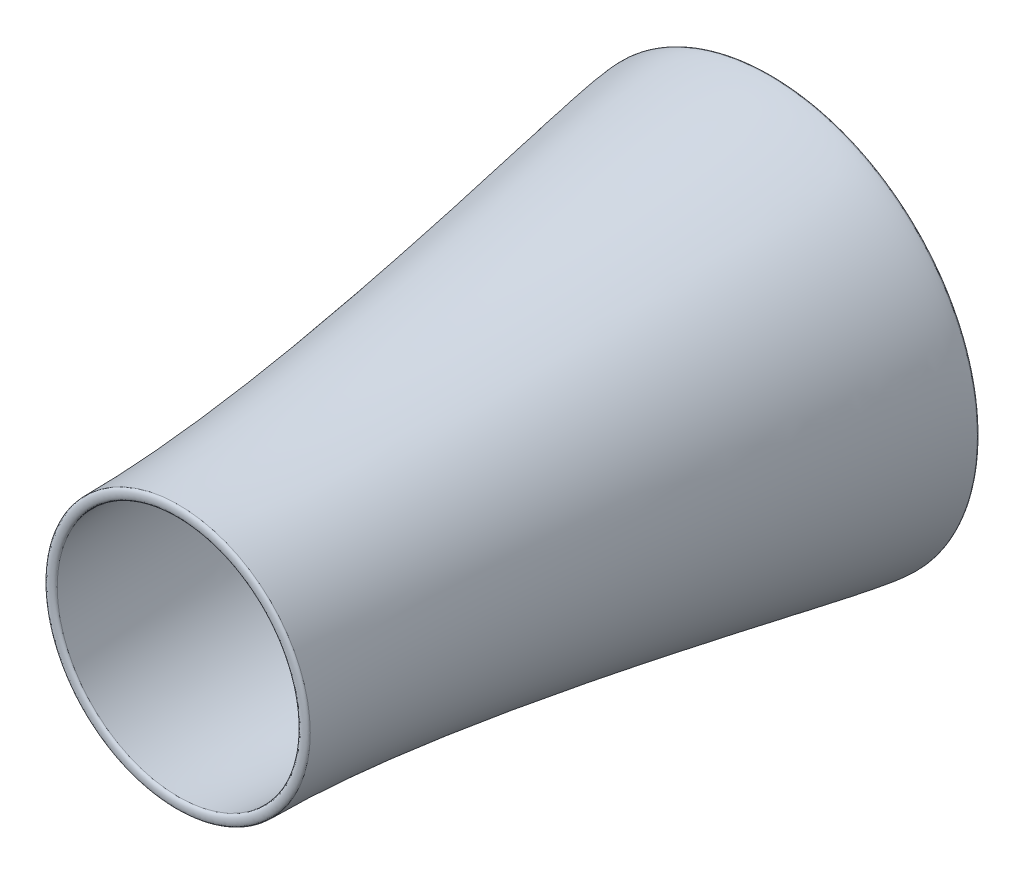
from build123d import *


with BuildPart() as part:
    # Sketch21 → Revolve2 (revolve)
    with BuildSketch(Plane(origin=(0, 0, 0), x_dir=(1, 0, 0), z_dir=(0, 1, 0))):
        with BuildLine():
            Line((-414.489662379, -2018.659396945), (-450.143329298, -2018.659396945))
            add(Edge.make_bspline(
                [(-711.609923736, -0.893759873), (-711.609923736, -126.27771225), (-450.143329298, -1288.35027656), (-450.143329298, -2018.659396945)],
                knots=[0, 0, 0, 0, 1, 1, 1, 1], degree=3))
            Line((-711.609923736, -0.893759873), (-622.148368512, -0.893759873))
            add(Edge.make_bspline(
                [(-622.148368512, -0.893759873), (-512.587421425, -283.558787507), (-414.972940266, -786.375242865), (-442.508967605, -1553.960293497), (-414.489662379, -2018.659396945)],
                knots=[0, 0, 0, 0, 0.206506907, 1, 1, 1, 1], degree=3))
        make_face()
    revolve(axis=Axis((0, 0, 99.684784321), (0, 0, -1)))


with BuildPart() as body_2:
    # Sketch22 → Revolve3 (revolve)
    with BuildSketch(Plane(origin=(0, 0, 0), x_dir=(1, 0, 0), z_dir=(0, 1, 0))):
        with BuildLine():
            Line((-711.609923736, -0.893759873), (-622.148368512, -0.893759873))
            add(Edge.make_bspline(
                [(-711.609923736, -0.893759873), (-711.609923736, 16.03957346), (-622.148368512, 16.03957346), (-622.148368512, -0.893759873)],
                knots=[0, 0, 0, 0, 1, 1, 1, 1], degree=3))
        make_face()
    revolve(axis=Axis((0, 0, 99.684784321), (0, 0, -1)))


with BuildPart() as body_3:
    # Sketch23 → Revolve4 (revolve)
    with BuildSketch(Plane(origin=(0, 0, 0), x_dir=(1, 0, 0), z_dir=(0, 1, 0))):
        with BuildLine():
            Line((-450.143329298, -2018.659396945), (-414.489662379, -2018.659396945))
            add(Edge.make_bspline(
                [(-450.143329298, -2018.659396945), (-450.143329298, -2031.359396945), (-414.489662379, -2031.359396945), (-414.489662379, -2018.659396945)],
                knots=[0, 0, 0, 0, 1, 1, 1, 1], degree=3))
        make_face()
    revolve(axis=Axis((0, 0, 1104.756830123), (0, 0, -1)))


solid = Compound([part.part, body_2.part, body_3.part])
